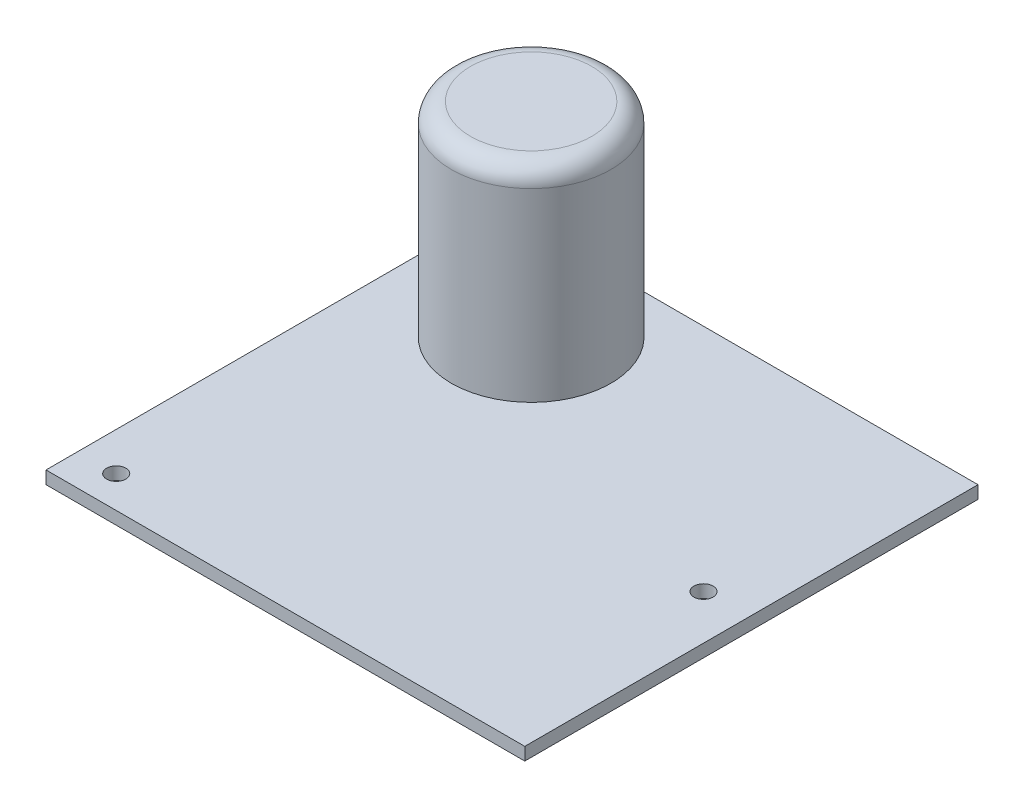
from build123d import *

# Parameters (mm, degrees)
ESQUISSE1_W        = 75
ESQUISSE1_H        = 71
ESQUISSE1_R        = 1.5
BOSS_EXTRU_1_DEPTH = 2
ESQUISSE3_R        = 12.5
BOSS_EXTRU_2_DEPTH = 32
CONG_1_R           = 3


with BuildPart() as part:
    # Esquisse1 → Boss.-Extru.1 (new body)
    with BuildSketch(Plane(origin=(0, 0, 0), x_dir=(1, 0, 0), z_dir=(0, 1, 0))):
        with Locations((0, -0.5)):
            Rectangle(ESQUISSE1_W, ESQUISSE1_H)
        with Locations((-31.5, 30)):
            Circle(ESQUISSE1_R, mode=Mode.SUBTRACT)
        with Locations((-31.5, -31)):
            Circle(ESQUISSE1_R, mode=Mode.SUBTRACT)
        with Locations((30.5, -1)):
            Circle(ESQUISSE1_R, mode=Mode.SUBTRACT)
    extrude(amount=BOSS_EXTRU_1_DEPTH)

    # Esquisse3 → Boss.-Extru.2 (add)
    with BuildSketch(Plane(origin=(0, 2, 0), x_dir=(1, 0, 0), z_dir=(0, 1, 0))):
        with Locations((-17.5, 20)):
            Circle(ESQUISSE3_R)
    extrude(amount=BOSS_EXTRU_2_DEPTH)

    # Congé1
    cong_1_edges = [part.edges().sort_by_distance(p)[0] for p in [
        (-30, 34, -20),
    ]]
    fillet(cong_1_edges, radius=CONG_1_R)


solid = part.part
